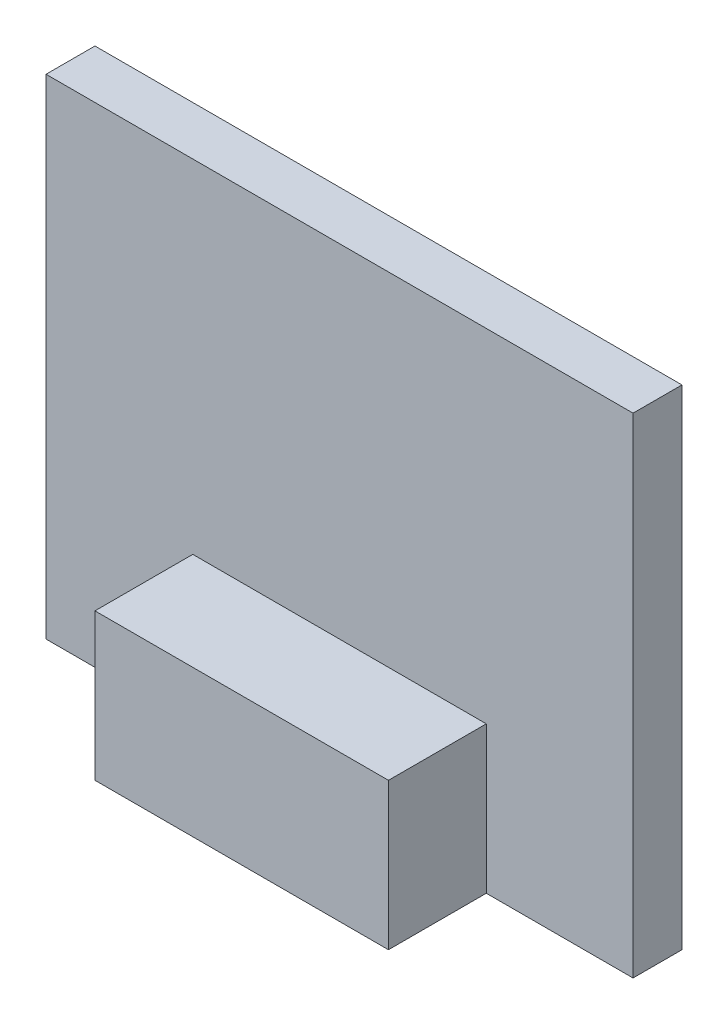
from build123d import *

# Parameters (mm, degrees)
SKETCH1_W           = 76.2
SKETCH1_H           = 63.5
BOSS_EXTRUDE1_DEPTH = 6.35
SKETCH2_W           = 38.1
SKETCH2_H           = 19.05
BOSS_EXTRUDE2_DEPTH = 12.7


with BuildPart() as part:
    # Sketch1 → Boss-Extrude1 (new body)
    with BuildSketch(Plane.XY):
        Rectangle(SKETCH1_W, SKETCH1_H)
    extrude(amount=BOSS_EXTRUDE1_DEPTH)

    # Sketch2 → Boss-Extrude2 (add)
    with BuildSketch(Plane.XY.offset(6.35)):
        with Locations((0, -22.225)):
            Rectangle(SKETCH2_W, SKETCH2_H)
    extrude(amount=BOSS_EXTRUDE2_DEPTH)


solid = part.part
